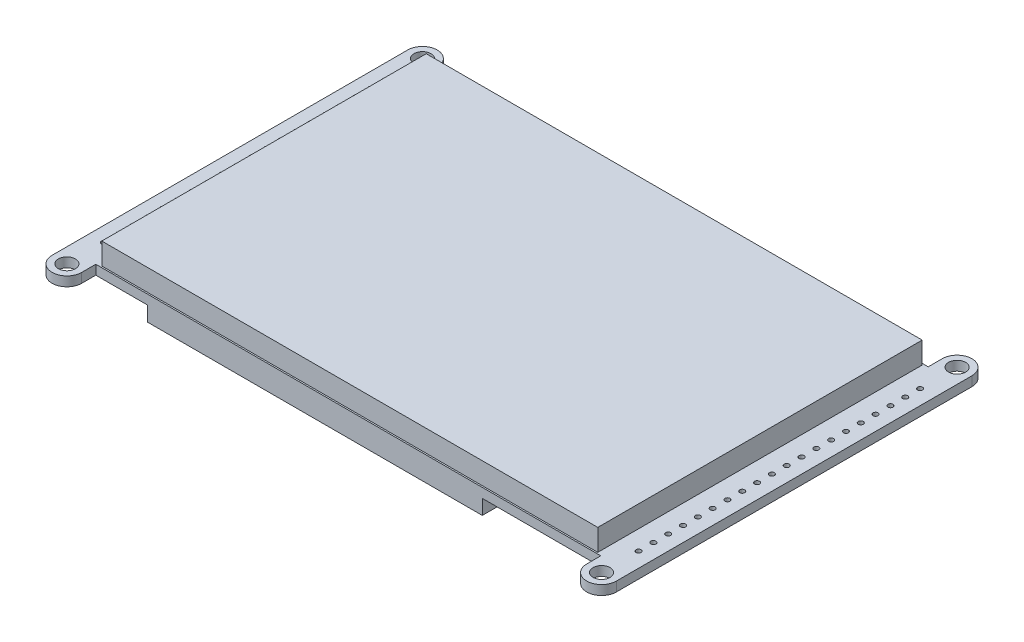
from build123d import *

# Parameters (mm, degrees)
SKETCH1_R           = 1.4605
SKETCH1_R_2         = 0.4318
SKETCH1_W           = 85.0392
SKETCH1_H           = 55.626
BOSS_EXTRUDE1_DEPTH = 1.6256
SKETCH1_2_W         = 85.0392
SKETCH1_2_H         = 55.626
BOSS_EXTRUDE2_DEPTH = 5.334
SKETCH2_W           = 57.3786
SKETCH2_H           = 56.134
BOSS_EXTRUDE3_DEPTH = 2.54


with BuildPart() as part:
    # Sketch1 → Boss-Extrude1 (new body)
    with BuildSketch(Plane(origin=(0, 0, 0), x_dir=(1, 0, 0), z_dir=(0, 1, 0))):
        with BuildLine():
            Line((43.2943, 28.067), (-43.2943, 28.067))
            Line((-43.2943, 28.067), (-43.2943, 30.48))
            ThreePointArc((-43.2943, 30.48), (-45.8343, 33.02), (-48.3743, 30.48))
            Line((-48.3743, 30.48), (-48.3743, -30.48))
            ThreePointArc((-48.3743, -30.48), (-45.8343, -33.02), (-43.2943, -30.48))
            Line((-43.2943, -30.48), (-43.2943, -28.067))
            Line((-43.2943, -28.067), (43.2943, -28.067))
            Line((43.2943, -28.067), (43.2943, -30.48))
            ThreePointArc((43.2943, -30.48), (45.8343, -33.02), (48.3743, -30.48))
            Line((48.3743, -30.48), (48.3743, 30.48))
            ThreePointArc((48.3743, 30.48), (45.8343, 33.02), (43.2943, 30.48))
            Line((43.2943, 30.48), (43.2943, 28.067))
        make_face()
        with Locations((-45.8343, 30.48)):
            Circle(SKETCH1_R, mode=Mode.SUBTRACT)
        with Locations((-45.8343, -30.48)):
            Circle(SKETCH1_R, mode=Mode.SUBTRACT)
        with Locations((45.8343, -30.48)):
            Circle(SKETCH1_R, mode=Mode.SUBTRACT)
        with Locations((45.8343, 30.48)):
            Circle(SKETCH1_R, mode=Mode.SUBTRACT)
        with Locations((-45.8343, 24.13)):
            Circle(SKETCH1_R_2, mode=Mode.SUBTRACT)
        with Locations((-45.8343, 21.59)):
            Circle(SKETCH1_R_2, mode=Mode.SUBTRACT)
        with Locations((-45.8343, 19.05)):
            Circle(SKETCH1_R_2, mode=Mode.SUBTRACT)
        with Locations((-45.8343, 16.51)):
            Circle(SKETCH1_R_2, mode=Mode.SUBTRACT)
        with Locations((-45.8343, 13.97)):
            Circle(SKETCH1_R_2, mode=Mode.SUBTRACT)
        with Locations((-45.8343, 11.43)):
            Circle(SKETCH1_R_2, mode=Mode.SUBTRACT)
        with Locations((-45.8343, 8.89)):
            Circle(SKETCH1_R_2, mode=Mode.SUBTRACT)
        with Locations((-45.8343, 6.35)):
            Circle(SKETCH1_R_2, mode=Mode.SUBTRACT)
        with Locations((-45.8343, 3.81)):
            Circle(SKETCH1_R_2, mode=Mode.SUBTRACT)
        with Locations((-45.8343, 1.27)):
            Circle(SKETCH1_R_2, mode=Mode.SUBTRACT)
        with Locations((-45.8343, -1.27)):
            Circle(SKETCH1_R_2, mode=Mode.SUBTRACT)
        with Locations((-45.8343, -3.81)):
            Circle(SKETCH1_R_2, mode=Mode.SUBTRACT)
        with Locations((-45.8343, -6.35)):
            Circle(SKETCH1_R_2, mode=Mode.SUBTRACT)
        with Locations((-45.8343, -8.89)):
            Circle(SKETCH1_R_2, mode=Mode.SUBTRACT)
        with Locations((-45.8343, -11.43)):
            Circle(SKETCH1_R_2, mode=Mode.SUBTRACT)
        with Locations((-45.8343, -13.97)):
            Circle(SKETCH1_R_2, mode=Mode.SUBTRACT)
        with Locations((-45.8343, -16.51)):
            Circle(SKETCH1_R_2, mode=Mode.SUBTRACT)
        with Locations((-45.8343, -19.05)):
            Circle(SKETCH1_R_2, mode=Mode.SUBTRACT)
        with Locations((-45.8343, -21.59)):
            Circle(SKETCH1_R_2, mode=Mode.SUBTRACT)
        with Locations((-45.8343, -24.13)):
            Circle(SKETCH1_R_2, mode=Mode.SUBTRACT)
        with Locations((45.8343, -24.13)):
            Circle(SKETCH1_R_2, mode=Mode.SUBTRACT)
        with Locations((45.8343, -21.59)):
            Circle(SKETCH1_R_2, mode=Mode.SUBTRACT)
        with Locations((45.8343, -19.05)):
            Circle(SKETCH1_R_2, mode=Mode.SUBTRACT)
        with Locations((45.8343, -16.51)):
            Circle(SKETCH1_R_2, mode=Mode.SUBTRACT)
        with Locations((45.8343, -13.97)):
            Circle(SKETCH1_R_2, mode=Mode.SUBTRACT)
        with Locations((45.8343, -11.43)):
            Circle(SKETCH1_R_2, mode=Mode.SUBTRACT)
        with Locations((45.8343, -8.89)):
            Circle(SKETCH1_R_2, mode=Mode.SUBTRACT)
        with Locations((45.8343, -6.35)):
            Circle(SKETCH1_R_2, mode=Mode.SUBTRACT)
        with Locations((45.8343, -3.81)):
            Circle(SKETCH1_R_2, mode=Mode.SUBTRACT)
        with Locations((45.8343, -1.27)):
            Circle(SKETCH1_R_2, mode=Mode.SUBTRACT)
        with Locations((45.8343, 1.27)):
            Circle(SKETCH1_R_2, mode=Mode.SUBTRACT)
        with Locations((45.8343, 3.81)):
            Circle(SKETCH1_R_2, mode=Mode.SUBTRACT)
        with Locations((45.8343, 6.35)):
            Circle(SKETCH1_R_2, mode=Mode.SUBTRACT)
        with Locations((45.8343, 8.89)):
            Circle(SKETCH1_R_2, mode=Mode.SUBTRACT)
        with Locations((45.8343, 11.43)):
            Circle(SKETCH1_R_2, mode=Mode.SUBTRACT)
        with Locations((45.8343, 13.97)):
            Circle(SKETCH1_R_2, mode=Mode.SUBTRACT)
        with Locations((45.8343, 16.51)):
            Circle(SKETCH1_R_2, mode=Mode.SUBTRACT)
        with Locations((45.8343, 19.05)):
            Circle(SKETCH1_R_2, mode=Mode.SUBTRACT)
        with Locations((45.8343, 21.59)):
            Circle(SKETCH1_R_2, mode=Mode.SUBTRACT)
        with Locations((45.8343, 24.13)):
            Circle(SKETCH1_R_2, mode=Mode.SUBTRACT)
        Rectangle(SKETCH1_W, SKETCH1_H, mode=Mode.SUBTRACT)
    extrude(amount=BOSS_EXTRUDE1_DEPTH)

    # Sketch1_2 → Boss-Extrude2 (add)
    with BuildSketch(Plane(origin=(0, 0, 0), x_dir=(1, 0, 0), z_dir=(0, 1, 0))):
        Rectangle(SKETCH1_2_W, SKETCH1_2_H)
    extrude(amount=BOSS_EXTRUDE2_DEPTH)

    # Sketch2 → Boss-Extrude3 (add)
    with BuildSketch(Plane.XZ):
        with Locations((-5.715, 0)):
            Rectangle(SKETCH2_W, SKETCH2_H)
    extrude(amount=BOSS_EXTRUDE3_DEPTH)


solid = part.part
